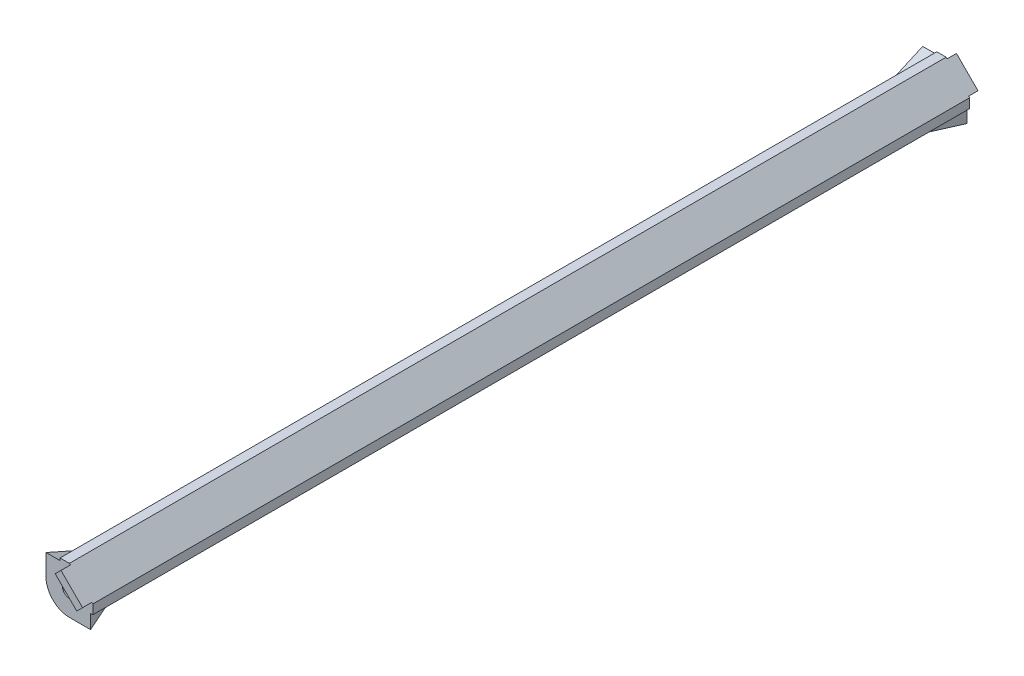
from build123d import *

# Parameters (mm, degrees)
BOSS_EXTRUDE1_DEPTH      = 187
SKETCH3_R                = 1.5
CUT_EXTRUDE2_DEPTH       = 188
CUT_EXTRUDE1_DEPTH       = 3
BOSS_EXTRUDE2_DEPTH      = 2
BOSS_EXTRUDE2_DEPTH_BACK = 189


with BuildPart() as part:
    # Sketch1 → Boss-Extrude1 (new body)
    with BuildSketch(Plane.XY):
        with BuildLine():
            Line((0, 0), (0, 5))
            Line((0, 5), (5, 5))
            Line((5, 5), (10, 0))
            Line((10, 0), (10, -5))
            Line((10, -5), (5, -5))
            ThreePointArc((5, -5), (1.464466094, -3.535533906), (0, 0))
        make_face()
    extrude(amount=BOSS_EXTRUDE1_DEPTH)

    # Sketch3 → Cut-Extrude2 (cut, through all)
    with BuildSketch(Plane.XY.offset(187)):
        with Locations((5, 0)):
            Circle(SKETCH3_R)
    extrude(amount=-CUT_EXTRUDE2_DEPTH, mode=Mode.SUBTRACT)

    # Sketch2 → Cut-Extrude1 (cut)
    with BuildSketch(Plane.ZY):
        Polygon((178, 0.5), (9, 0.5), (0, 4.5), (0, 5), (187, 5), (187, 4.5), align=None)
    cut_extrude1 = extrude(amount=-CUT_EXTRUDE1_DEPTH, mode=Mode.SUBTRACT)

    # Mirror1: Cut-Extrude1 across plane
    add(cut_extrude1.mirror(Plane(origin=(2.5, -2.5, 0), x_dir=(0, 0, 1), z_dir=(-0.707106781, 0.707106781, 0))), mode=Mode.SUBTRACT)

    # Sketch4 → Boss-Extrude2 (add, two sides)
    with BuildSketch(Plane.XY.offset(187)) as boss_extrude2_sk:
        Polygon((5.201902961, 4.798097039), (9.798097039, 0.201902961), (8.560660172, -1.035533906), (3.964466094, 3.560660172), align=None)
    extrude(amount=BOSS_EXTRUDE2_DEPTH)
    extrude(boss_extrude2_sk.sketch, amount=-BOSS_EXTRUDE2_DEPTH_BACK)


solid = part.part
